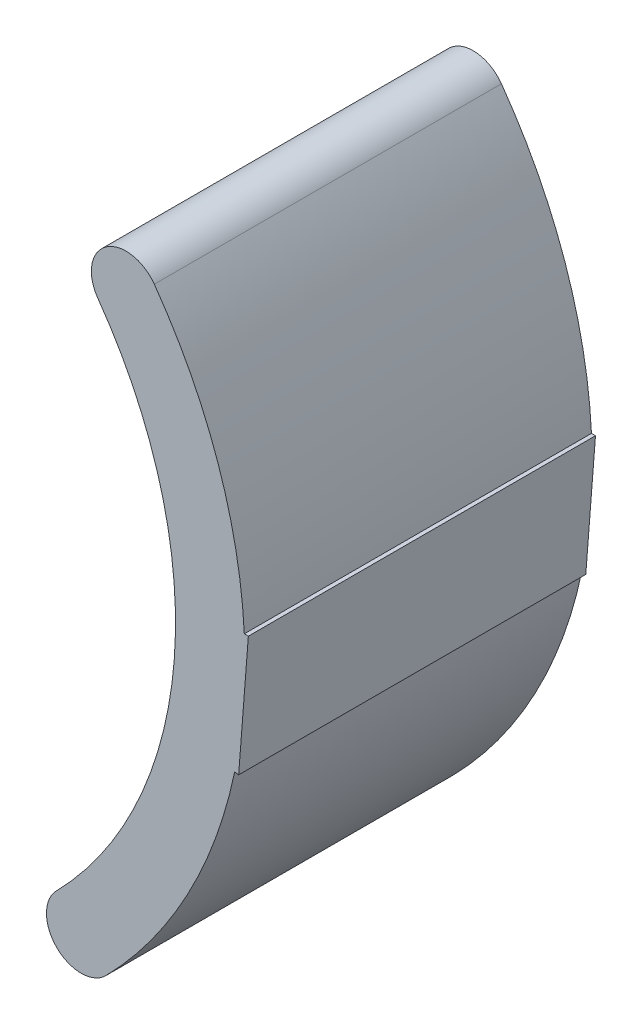
from build123d import *

# Parameters (mm, degrees)
BOSS_EXTRU_1_DEPTH = 50


with BuildPart() as part:
    # Esquisse1 → Boss.-Extru.1 (new body)
    with BuildSketch(Plane.XY):
        with BuildLine():
            Line((69.091744654, -14.415915473), (70.48859579, 3.584084527))
            Line((70.48859579, 3.584084527), (69.908185058, 3.584084527))
            ThreePointArc((69.908185058, 3.584084527), (66.086740028, 23.076888708), (56.943655444, 40.711424744))
            ThreePointArc((56.943655444, 40.711424744), (49.968292573, 41.870869794), (48.808847523, 34.895506923))
            ThreePointArc((48.808847523, 34.895506923), (59.820145904, -4.642213263), (42.84093319, -42.007790271))
            ThreePointArc((42.84093319, -42.007790271), (42.910361767, -49.078517226), (49.981088722, -49.009088649))
            ThreePointArc((49.981088722, -49.009088649), (61.735305745, -32.996242584), (68.518282775, -14.32637168))
            Line((68.518282775, -14.32637168), (69.091744654, -14.415915473))
        make_face()
    extrude(amount=BOSS_EXTRU_1_DEPTH)


solid = part.part
